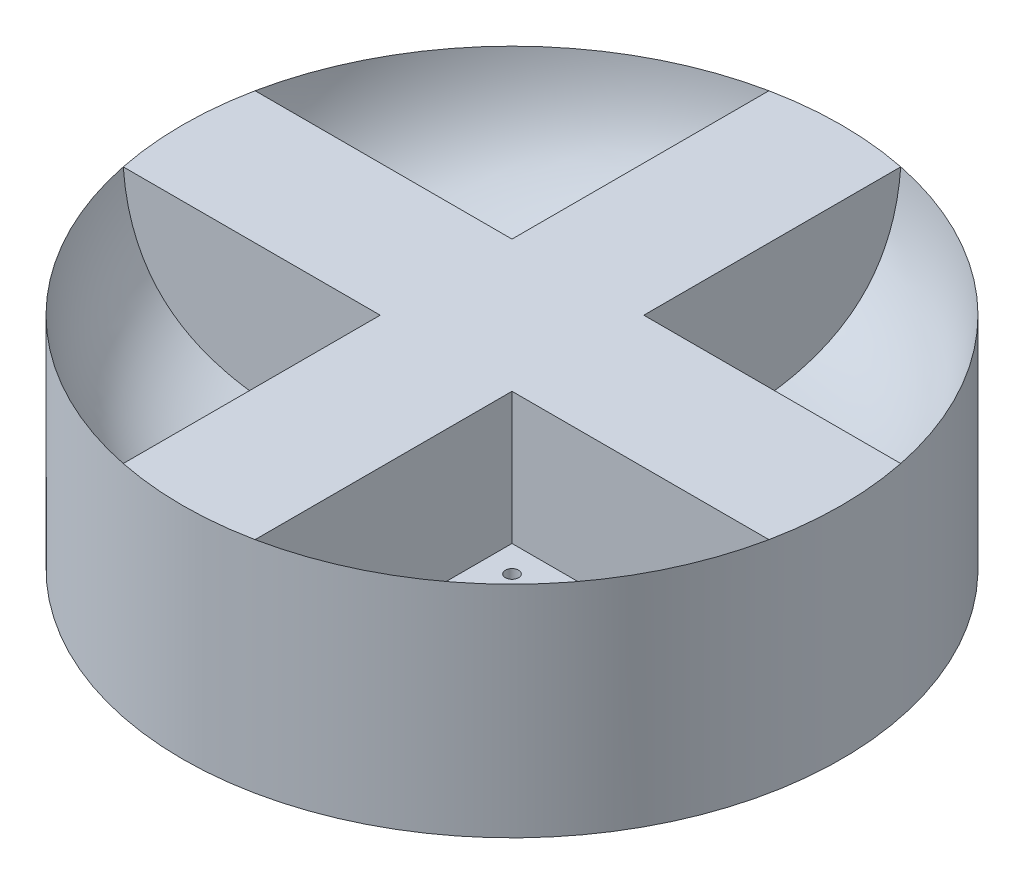
from build123d import *

# Parameters (mm, degrees)
SKETCH1_R           = 37.5
BOSS_EXTRUDE1_DEPTH = 10
BOSS_EXTRUDE2_DEPTH = 15
SKETCH8_R           = 0.75
CUT_EXTRUDE1_DEPTH  = 11


with BuildPart() as part:
    # Sketch1 → Boss-Extrude1 (new body)
    with BuildSketch(Plane(origin=(0, 0, 0), x_dir=(1, 0, 0), z_dir=(0, 1, 0))):
        Circle(SKETCH1_R)
    extrude(amount=BOSS_EXTRUDE1_DEPTH)

    # Sketch5 → Revolve1 (revolve)
    with BuildSketch(Plane(origin=(0, 0, 0), x_dir=(0, 0, -1), z_dir=(1, 0, 0))):
        with BuildLine():
            Line((-37.5, 25), (-37.5, 10))
            Line((-37.5, 10), (-22.5, 10))
            add(Edge.make_bspline(
                [(-37.5, 25), (-36.468402779, 11.405172281), (-22.5, 10)],
                knots=[0, 0, 0, 1, 1, 1], degree=2))
        make_face()
    revolve(axis=Axis((0, 0, 0), (0, 1, 0)))

    # Sketch7 → Boss-Extrude2 (add)
    with BuildSketch(Plane(origin=(0, 10, 0), x_dir=(1, 0, 0), z_dir=(0, 1, 0))):
        with BuildLine():
            Line((36.742346142, 7.5), (7.5, 7.5))
            Line((7.5, 7.5), (7.5, 36.742346142))
            ThreePointArc((7.5, 36.742346142), (0, 37.5), (-7.5, 36.742346142))
            Line((-7.5, 36.742346142), (-7.5, 7.5))
            Line((-7.5, 7.5), (-36.742346142, 7.5))
            ThreePointArc((-36.742346142, 7.5), (-37.5, 0), (-36.742346142, -7.5))
            Line((-36.742346142, -7.5), (-7.5, -7.5))
            Line((-7.5, -7.5), (-7.5, -36.742346142))
            ThreePointArc((-7.5, -36.742346142), (0, -37.5), (7.5, -36.742346142))
            Line((7.5, -36.742346142), (7.5, -7.5))
            Line((7.5, -7.5), (36.742346142, -7.5))
            ThreePointArc((36.742346142, -7.5), (37.5, 0), (36.742346142, 7.5))
        make_face()
    extrude(amount=BOSS_EXTRUDE2_DEPTH)

    # Sketch8 → Cut-Extrude1 (cut, through all)
    with BuildSketch(Plane(origin=(0, 10, 0), x_dir=(1, 0, 0), z_dir=(0, 1, 0))):
        with Locations((-10.50286976, 10.50286976)):
            Circle(SKETCH8_R)
        with Locations((-12.907032816, 12.907032816)):
            Circle(SKETCH8_R)
        with Locations((10.50286976, 10.50286976)):
            Circle(SKETCH8_R)
        with Locations((12.907032816, 12.907032816)):
            Circle(SKETCH8_R)
        with Locations((10.50286976, -10.50286976)):
            Circle(SKETCH8_R)
        with Locations((12.907032816, -12.907032816)):
            Circle(SKETCH8_R)
        with Locations((-10.50286976, -10.50286976)):
            Circle(SKETCH8_R)
        with Locations((-12.907032816, -12.907032816)):
            Circle(SKETCH8_R)
    extrude(amount=-CUT_EXTRUDE1_DEPTH, mode=Mode.SUBTRACT)


solid = part.part
